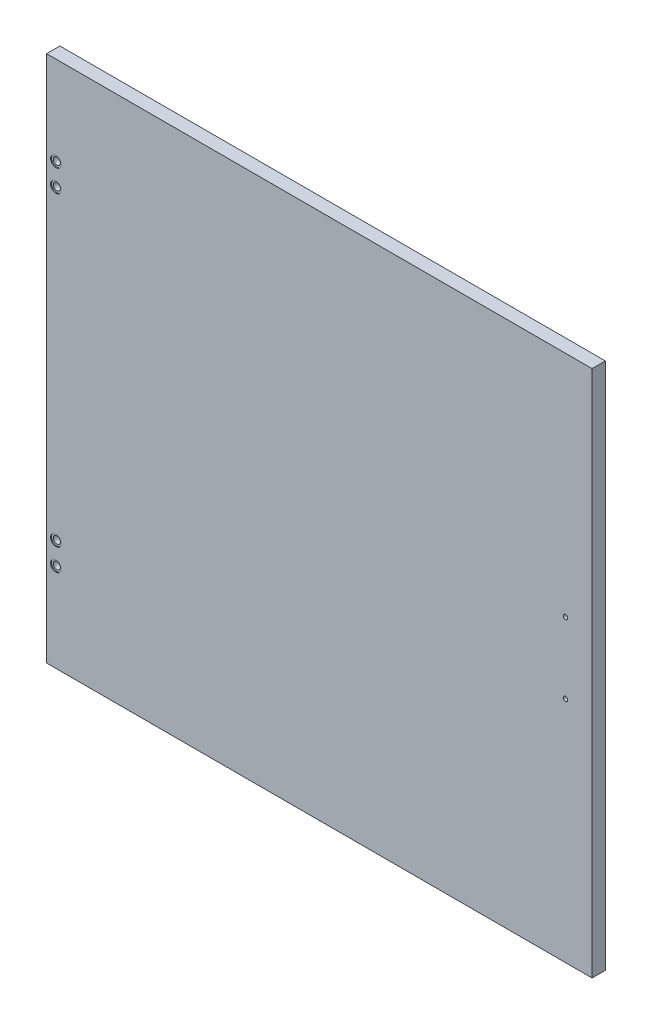
from build123d import *

# Parameters (mm, degrees)
SKETCH_1_W          = 615
SKETCH_1_H          = 595
EXTRUDE_1_DEPTH     = 15
SKETCH_2_R          = 4
CUT_EXTRUDE_2_DEPTH = 429.120894141
SKETCH_3_R          = 6
CUT_EXTRUDE_4_DEPTH = 1
SKETCH_4_R          = 2.5
CUT_EXTRUDE_5_DEPTH = 429.120894141
SKETCH_5_R          = 2
CUT_EXTRUDE_6_DEPTH = 9


with BuildPart() as part:
    # ｽｹｯﾁ1 → ﾎﾞｽ - 押し出し1 (new body)
    with BuildSketch(Plane.XY):
        Rectangle(SKETCH_1_W, SKETCH_1_H)
    extrude(amount=EXTRUDE_1_DEPTH)

    # ｽｹｯﾁ2 → ｶｯﾄ - 押し出し2 (cut, through all)
    with BuildSketch(Plane.XY.offset(15)):
        with Locations((-297, 197.5)):
            Circle(SKETCH_2_R)
        with Locations((-297, 172.5)):
            Circle(SKETCH_2_R)
    cut_extrude_2 = extrude(amount=-CUT_EXTRUDE_2_DEPTH, mode=Mode.SUBTRACT)

    # ﾐﾗｰ2: ｶｯﾄ - 押し出し2 across plane
    add(cut_extrude_2.mirror(Plane.ZX), mode=Mode.SUBTRACT)

    # ｽｹｯﾁ3 → ｶｯﾄ - 押し出し4 (cut)
    with BuildSketch(Plane.XY.offset(15)):
        with Locations((-297, 197.5)):
            Circle(SKETCH_3_R)
        with Locations((-297, 172.5)):
            Circle(SKETCH_3_R)
    cut_extrude_4 = extrude(amount=-CUT_EXTRUDE_4_DEPTH, mode=Mode.SUBTRACT)

    # ﾐﾗｰ4: ｶｯﾄ - 押し出し4 across plane
    add(cut_extrude_4.mirror(Plane.ZX), mode=Mode.SUBTRACT)

    # ｽｹｯﾁ4 → ｶｯﾄ - 押し出し5 (cut, through all)
    with BuildSketch(Plane.XY.offset(15)):
        with Locations((277.5, 40)):
            Circle(SKETCH_4_R)
        with Locations((277.5, -40)):
            Circle(SKETCH_4_R)
    extrude(amount=-CUT_EXTRUDE_5_DEPTH, mode=Mode.SUBTRACT)

    # ｽｹｯﾁ5 → ｶｯﾄ - 押し出し6 (cut)
    with BuildSketch(Plane.XY):
        with Locations((298, 197.5)):
            Circle(SKETCH_5_R)
        with Locations((298, 167.5)):
            Circle(SKETCH_5_R)
    cut_extrude_6 = extrude(amount=CUT_EXTRUDE_6_DEPTH, mode=Mode.SUBTRACT)

    # ﾐﾗｰ5: ｶｯﾄ - 押し出し6 across plane
    add(cut_extrude_6.mirror(Plane.ZX), mode=Mode.SUBTRACT)


solid = part.part
